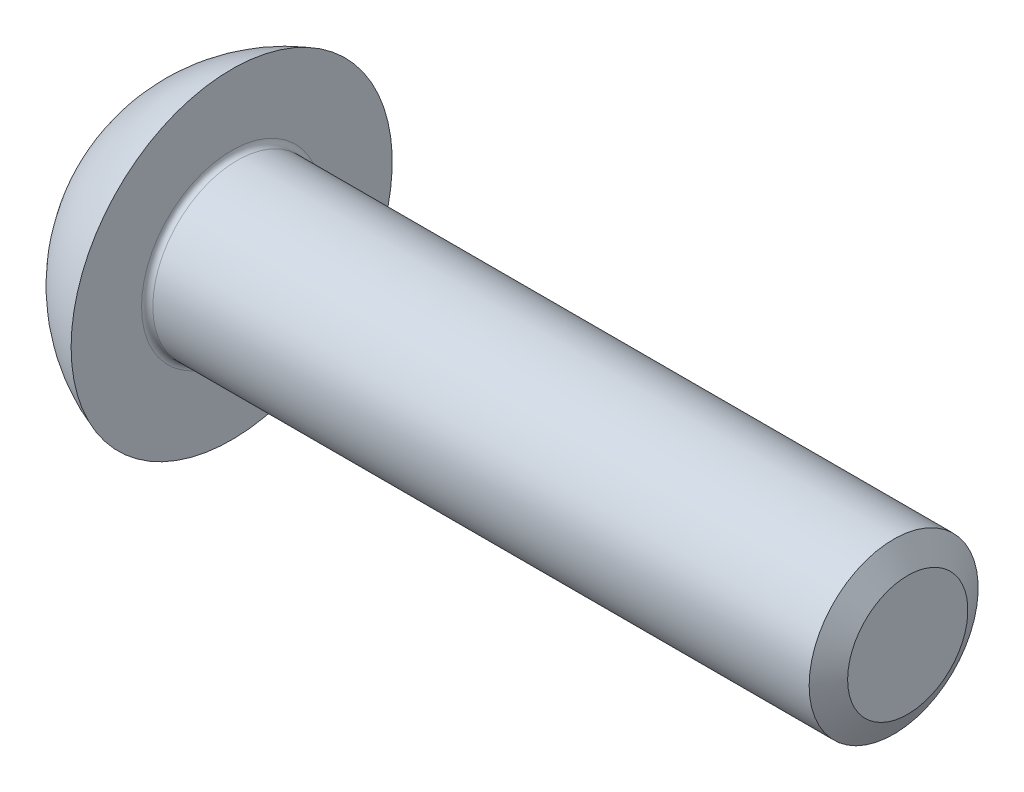
from build123d import *

# Parameters (mm, degrees)
CUT_EXTRUDE_1_DEPTH = 1.65


with BuildPart() as part:
    # 草图1 → 旋转1 (revolve)
    with BuildSketch(Plane.XY):
        with BuildLine():
            Line((0, 1.5), (-11.9, 1.5))
            ThreePointArc((-11.9, 1.5), (-11.970710678, 1.529289322), (-12, 1.6))
            Line((-12, 1.6), (-12, 2.85))
            ThreePointArc((-12, 2.85), (-12.948716751, 2.326209363), (-13.65, 1.5))
            Line((-13.65, 1.5), (-13.65, 0))
            Line((-13.65, 0), (0, 0))
            Line((0, 0), (0, 1.5))
        make_face()
    revolve(axis=Axis((-13.65, 0, 0), (1, 0, 0)))

    # 草图2 → 切除-拉伸1 (cut)
    with BuildSketch(Plane.ZY.offset(13.65)):
        Polygon((0, 1.154700538), (-1, 0.577350269), (-1, -0.577350269), (0, -1.154700538), (1, -0.577350269), (1, 0.577350269), align=None)
    extrude(amount=-CUT_EXTRUDE_1_DEPTH, mode=Mode.SUBTRACT)

    # 草图6 → 旋转2 (revolve)
    with BuildSketch(Plane.XY):
        Polygon((-12.61, 1.154700538), (-12, 0), (-11.7, 0), (-11.7, 1.154700538), align=None)
    revolve(axis=Axis((-13.65, 0, 0), (1, 0, 0)))

    # 草图7 → 切除-旋转5 (revolve, cut)
    with BuildSketch(Plane.XY):
        Polygon((-13.65, 1.154700538), (-13.35, 0), (-13.65, 0), align=None)
    revolve(axis=Axis((-13.65, 0, 0), (1, 0, 0)), mode=Mode.SUBTRACT)

    # 草图4 → 切除-旋转1 (revolve, cut)
    with BuildSketch(Plane.XY):
        Polygon((-0.25, 1.5), (0, 1.066987298), (0.25, 1.5), align=None)
    revolve(axis=Axis((-0.25, 0, 0), (1, 0, 0)), mode=Mode.SUBTRACT)


solid = part.part
